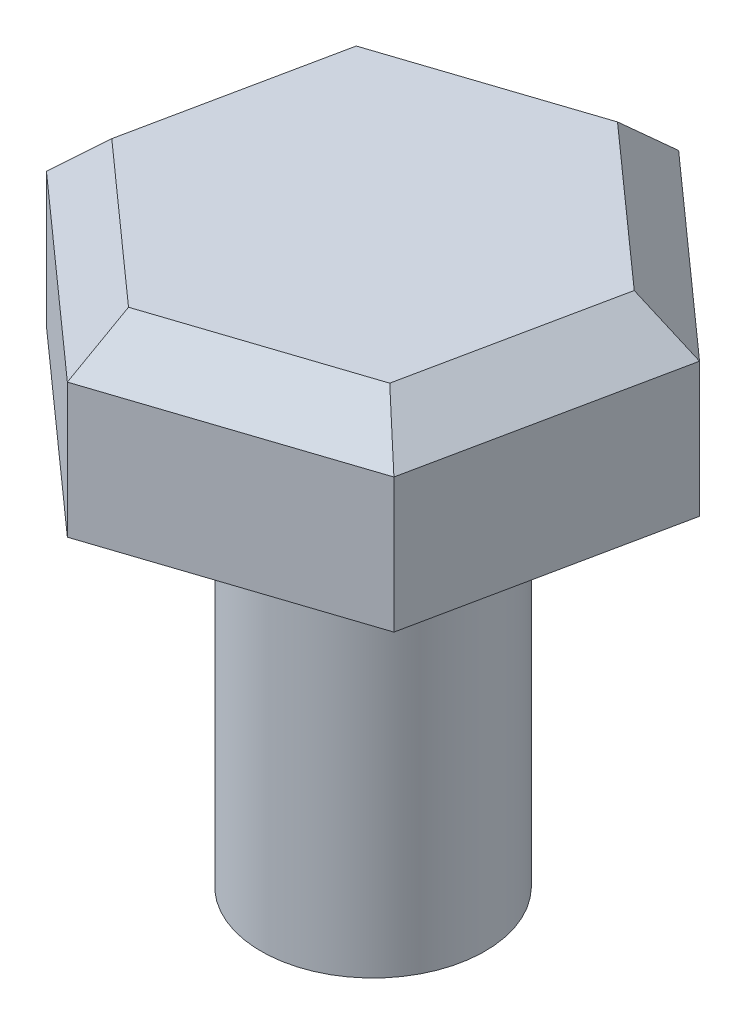
from build123d import *

# Parameters (mm, degrees)
BOSS_EXTRUDE1_DEPTH = 4
CHAMFER2_SIZE       = 1
SKETCH4_R           = 2.5
BOSS_EXTRUDE3_DEPTH = 9


with BuildPart() as part:
    # Sketch2 → Boss-Extrude1 (new body)
    with BuildSketch(Plane(origin=(0, 0, 0), x_dir=(1, 0, 0), z_dir=(0, 1, 0))):
        Polygon((5.482188976, 1.810783632), (1.172909862, 5.653106738), (-4.309279114, 3.842323106), (-5.482188976, -1.810783632), (-1.172909862, -5.653106738), (4.309279114, -3.842323106), align=None)
    extrude(amount=BOSS_EXTRUDE1_DEPTH)

    # Chamfer2
    chamfer2_edges = [part.edges().sort_by_distance(p)[0] for p in [
        (-1.568184626, 4, -4.747714922),
        (-4.895734045, 4, -1.015769737),
        (-3.327549419, 4, 3.731945185),
        (1.568184626, 4, 4.747714922),
        (4.895734045, 4, 1.015769737),
        (3.327549419, 4, -3.731945185),
    ]]
    chamfer(chamfer2_edges, length=CHAMFER2_SIZE)

    # Sketch4 → Boss-Extrude3 (add)
    with BuildSketch(Plane.XZ):
        Circle(SKETCH4_R)
    extrude(amount=BOSS_EXTRUDE3_DEPTH)


solid = part.part
